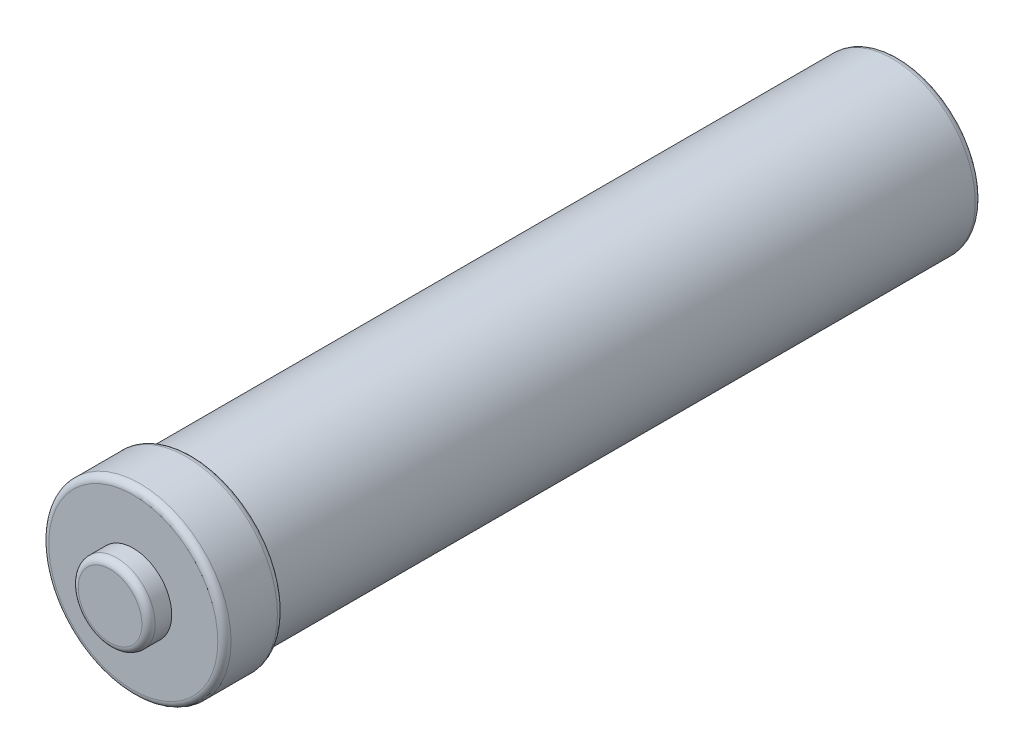
from build123d import *

# Parameters (mm, degrees)
SKETCH1_R           = 14.732
BOSS_EXTRUDE1_DEPTH = 8.89
SKETCH2_R           = 31.75
BOSS_EXTRUDE2_DEPTH = 270.51
SKETCH3_R           = 34.925
BOSS_EXTRUDE3_DEPTH = 22.86
FILLET1_R           = 2.54


with BuildPart() as part:
    # Sketch1 → Boss-Extrude1 (new body)
    with BuildSketch(Plane.XY):
        Circle(SKETCH1_R)
    boss_extrude1 = extrude(amount=BOSS_EXTRUDE1_DEPTH)

    # Sketch2 → Boss-Extrude2 (add)
    with BuildSketch(Plane.XY.offset(8.89)):
        Circle(SKETCH2_R)
    extrude(amount=BOSS_EXTRUDE2_DEPTH)

    # Sketch3 → Boss-Extrude3 (add)
    with BuildSketch(Plane.XY.offset(279.4)):
        Circle(SKETCH3_R)
    extrude(amount=BOSS_EXTRUDE3_DEPTH)

    # Mirror1: Boss-Extrude1 across plane
    add(boss_extrude1.mirror(Plane(origin=(0, 0, 155.575), x_dir=(1, 0, 0), z_dir=(0, 0, -1))))

    # Fillet1
    fillet1_edges = [part.edges().sort_by_distance(p)[0] for p in [
        (-14.732, 0, 311.15),
        (-14.732, 0, 0),
        (-31.75, 0, 8.89),
        (-34.925, 0, 279.4),
        (-34.925, 0, 302.26),
    ]]
    fillet(fillet1_edges, radius=FILLET1_R)


solid = part.part
